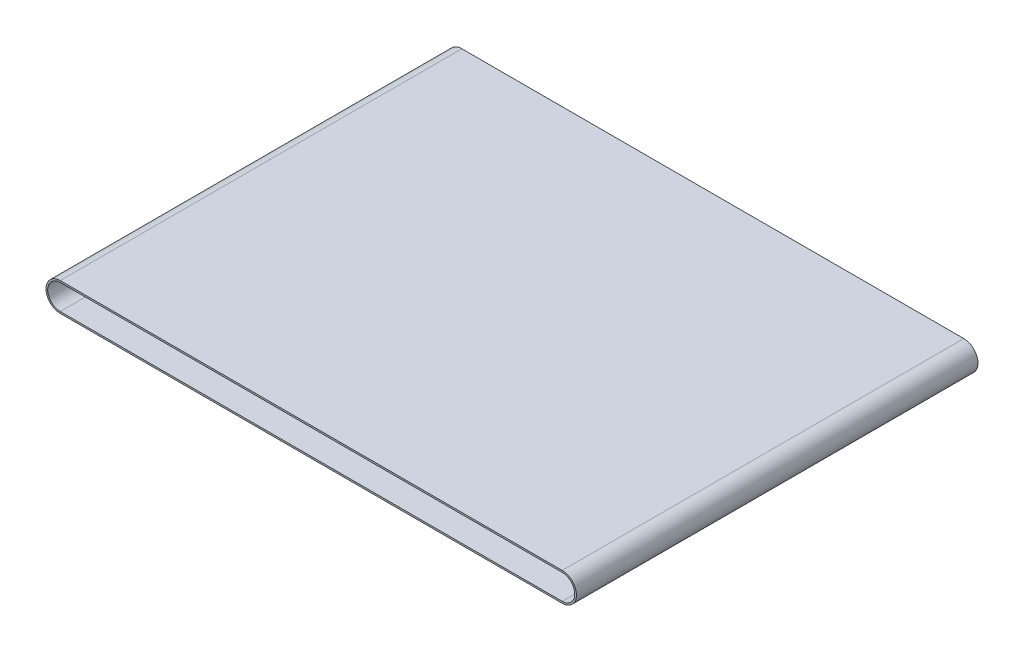
from build123d import *

# Parameters (mm, degrees)
BOSS_EXTRUDE1_DEPTH = 240


with BuildPart() as part:
    # Sketch1 → Boss-Extrude1 (new body)
    with BuildSketch(Plane.XY):
        with BuildLine():
            Line((-60.686830524, 26.788198472), (239.313169476, 26.788198472))
            ThreePointArc((239.313169476, 26.788198472), (247.813169476, 18.288198472), (239.313169476, 9.788198472))
            Line((239.313169476, 9.788198472), (-60.686830524, 9.788198472))
            ThreePointArc((-60.686830524, 9.788198472), (-69.186830524, 18.288198472), (-60.686830524, 26.788198472))
        make_face()
        with BuildLine():
            Line((-60.686830524, 10.788198472), (239.313169476, 10.788198472))
            ThreePointArc((239.313169476, 10.788198472), (246.813169476, 18.288198472), (239.313169476, 25.788198472))
            Line((239.313169476, 25.788198472), (-60.686830524, 25.788198472))
            ThreePointArc((-60.686830524, 25.788198472), (-68.186830524, 18.288198472), (-60.686830524, 10.788198472))
        make_face(mode=Mode.SUBTRACT)
    extrude(amount=BOSS_EXTRUDE1_DEPTH)


solid = part.part
